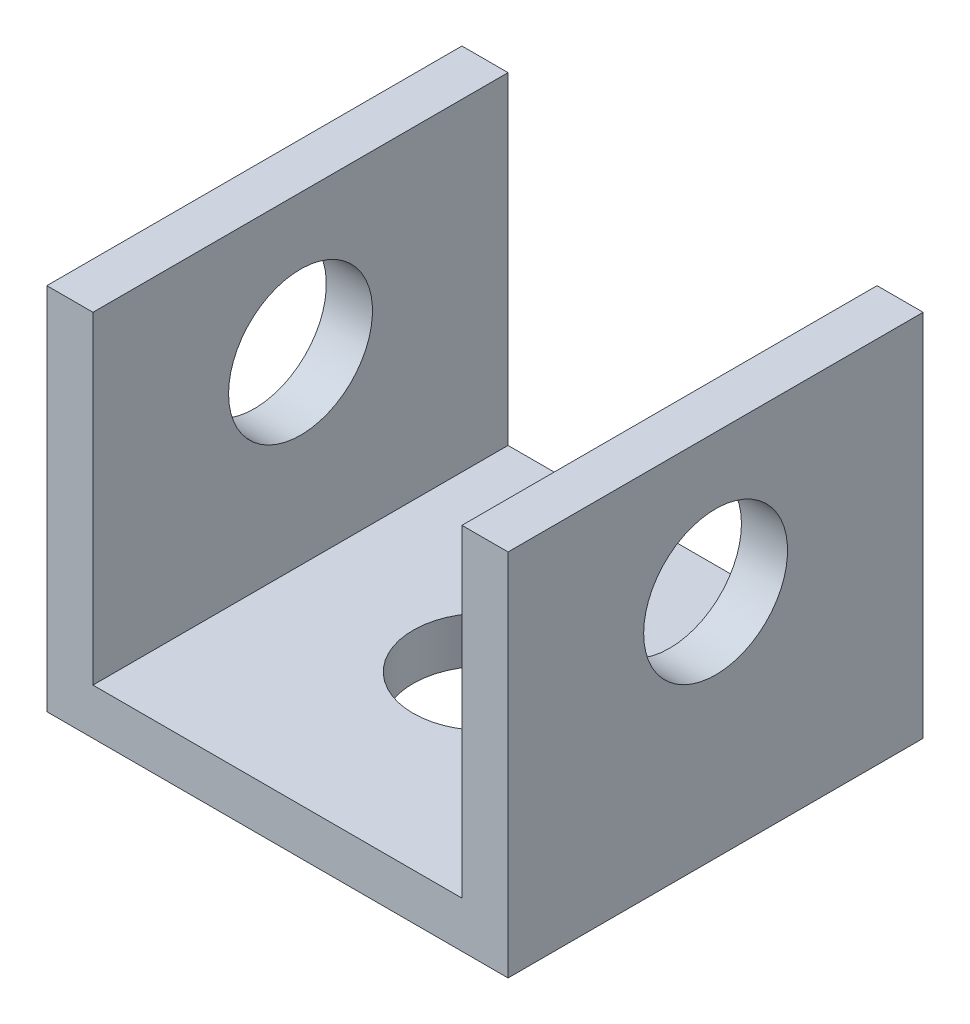
from build123d import *

# Parameters (mm, degrees)
SKETCH1_W           = 50
SKETCH1_H           = 45
BOSS_EXTRUDE1_DEPTH = 5
SKETCH5_W           = 5
SKETCH5_H           = 45
BOSS_EXTRUDE3_DEPTH = 35
SKETCH9_R           = 7.8
CUT_EXTRUDE5_DEPTH  = 10
SKETCH11_R          = 7.8
CUT_EXTRUDE8_DEPTH  = 51


with BuildPart() as part:
    # Sketch1 → Boss-Extrude1 (new body)
    with BuildSketch(Plane(origin=(0, 0, 0), x_dir=(1, 0, 0), z_dir=(0, 1, 0))):
        Rectangle(SKETCH1_W, SKETCH1_H)
    extrude(amount=BOSS_EXTRUDE1_DEPTH)

    # Sketch5 → Boss-Extrude3 (add)
    with BuildSketch(Plane(origin=(0, 5, 0), x_dir=(1, 0, 0), z_dir=(0, 1, 0))):
        with Locations((22.5, 0)):
            Rectangle(SKETCH5_W, SKETCH5_H)
        with Locations((-22.5, 0)):
            Rectangle(SKETCH5_W, SKETCH5_H)
    extrude(amount=BOSS_EXTRUDE3_DEPTH)

    # Sketch9 → Cut-Extrude5 (cut)
    with BuildSketch(Plane(origin=(0, 5, 0), x_dir=(1, 0, 0), z_dir=(0, 1, 0))):
        Circle(SKETCH9_R)
    extrude(amount=-CUT_EXTRUDE5_DEPTH, mode=Mode.SUBTRACT)

    # Sketch11 → Cut-Extrude8 (cut, through all)
    with BuildSketch(Plane.ZY.offset(25)):
        with Locations((0, 25)):
            Circle(SKETCH11_R)
    extrude(amount=-CUT_EXTRUDE8_DEPTH, mode=Mode.SUBTRACT)


solid = part.part
